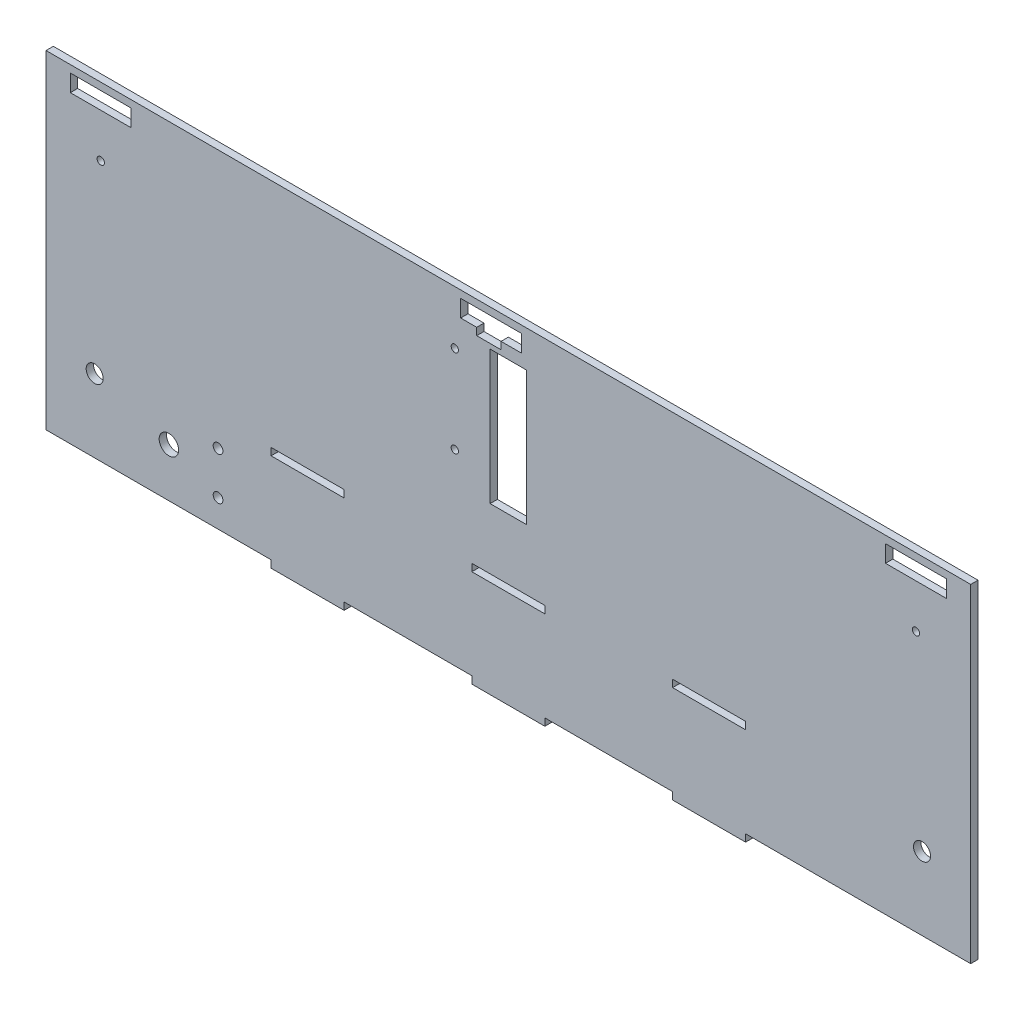
from build123d import *

# Parameters (mm, degrees)
CROQUIS1_R              = 2
CROQUIS1_R_2            = 3.5
CROQUIS1_R_3            = 4
CROQUIS1_W              = 30
CROQUIS1_H              = 3
CROQUIS1_R_4            = 1.5
CROQUIS1_W_2            = 15
CROQUIS1_H_2            = 55
SALIENTE_EXTRUIR4_DEPTH = 3


with BuildPart() as part:
    # Croquis1 → Saliente-Extruir4 (new body)
    with BuildSketch(Plane.XY):
        Polygon((-190, 67.5), (-190, -67.5), (-97.5, -67.5), (-97.5, -70.5), (-67.5, -70.5), (-67.5, -67.5), (-15, -67.5), (-15, -70.5), (15, -70.5), (15, -67.5), (67.5, -67.5), (67.5, -70.5), (97.5, -70.5), (97.5, -67.5), (190, -67.5), (190, 67.5), align=None)
        with Locations((-119.3, -56.25)):
            Circle(CROQUIS1_R, mode=Mode.SUBTRACT)
        with Locations((-170, -37.5)):
            Circle(CROQUIS1_R_2, mode=Mode.SUBTRACT)
        with Locations((-139.5, -47.5)):
            Circle(CROQUIS1_R_3, mode=Mode.SUBTRACT)
        with Locations((-119.3, -38.75)):
            Circle(CROQUIS1_R, mode=Mode.SUBTRACT)
        with Locations((-82.5, -29)):
            Rectangle(CROQUIS1_W, CROQUIS1_H, mode=Mode.SUBTRACT)
        with Locations((170, -37.5)):
            Circle(CROQUIS1_R_2, mode=Mode.SUBTRACT)
        with Locations((0, -29)):
            Rectangle(CROQUIS1_W, CROQUIS1_H, mode=Mode.SUBTRACT)
        with Locations((82.5, -29)):
            Rectangle(CROQUIS1_W, CROQUIS1_H, mode=Mode.SUBTRACT)
        with Locations((-22, 9.5)):
            Circle(CROQUIS1_R_4, mode=Mode.SUBTRACT)
        with Locations((0, 25)):
            Rectangle(CROQUIS1_W_2, CROQUIS1_H_2, mode=Mode.SUBTRACT)
        with Locations((-167.5, 39.5)):
            Circle(CROQUIS1_R_4, mode=Mode.SUBTRACT)
        Polygon((-180, 57.5), (-180, 64.5), (-155, 64.5), (-155, 57.5), (-163.4, 57.5), (-173.4, 57.5), align=None, mode=Mode.SUBTRACT)
        with Locations((-22, 45.5)):
            Circle(CROQUIS1_R_4, mode=Mode.SUBTRACT)
        Polygon((-19.6, 57.5), (-19.6, 64.5), (5.4, 64.5), (5.4, 57.5), (-3, 57.5), (-3, 54.5), (-13, 54.5), (-13, 57.5), align=None, mode=Mode.SUBTRACT)
        with Locations((167.5, 39.5)):
            Circle(CROQUIS1_R_4, mode=Mode.SUBTRACT)
        Polygon((155, 57.5), (155, 64.5), (180, 64.5), (180, 57.5), (171.6, 57.5), (161.6, 57.5), align=None, mode=Mode.SUBTRACT)
    extrude(amount=SALIENTE_EXTRUIR4_DEPTH)


solid = part.part
